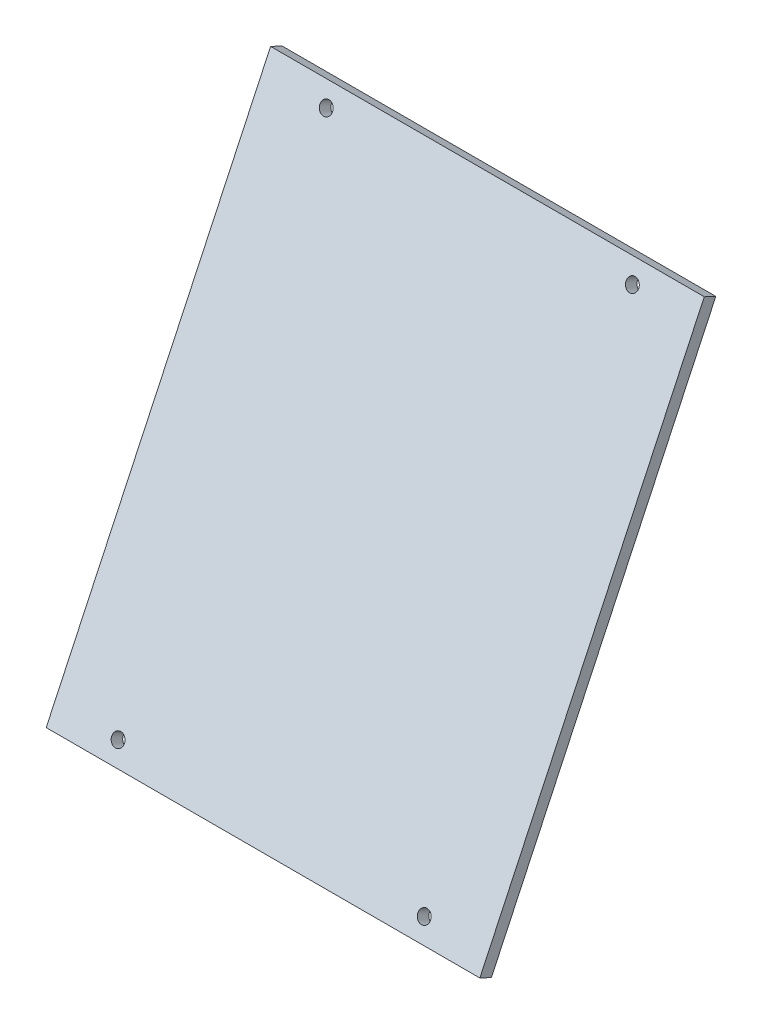
from build123d import *

# Parameters (mm, degrees)
BOSS_EXTRUDE1_DEPTH         = 215.9
F_1_4_0_25_DIAMETER_HOLE1_D = 6.35


with BuildPart() as part:
    # Sketch1 → Boss-Extrude1 (new body)
    with BuildSketch(Plane(origin=(0, 0, 0), x_dir=(0, 0, -1), z_dir=(1, 0, 0))):
        Polygon((0, 0), (111.727575693, 237.838071514), (105.980151385, 240.538), (-5.747424307, 2.699928486), align=None)
    extrude(amount=BOSS_EXTRUDE1_DEPTH)

    # 1/4 (0.25) Diameter Hole1 (through all)
    with Locations(Plane(origin=(0, 2.699928486, 5.747424307), x_dir=(1, 0, 0), z_dir=(0, 0.425185588, 0.90510619))):
        with Locations((31.75, 253.248665788), (184.15, 253.248665788), (184.15, 9.525), (31.75, 9.525)):
            Hole(F_1_4_0_25_DIAMETER_HOLE1_D / 2)


solid = part.part
